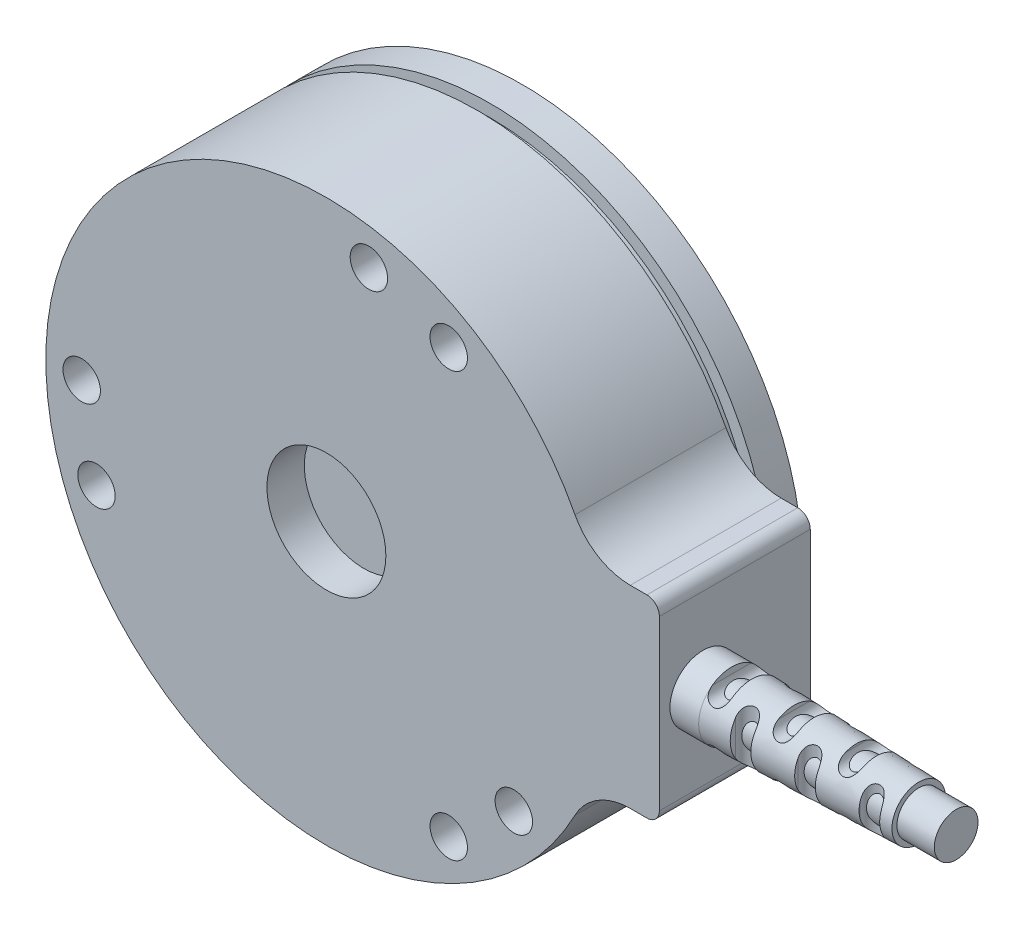
from build123d import *

# Parameters (mm, degrees)
SCHIZZO1_R                        = 1.5
ESTRUSIONE_ESTRUSIONE1_DEPTH      = 5
SCHIZZO2_R                        = 4.769
TAGLIO_ESTRUSIONE1_DEPTH          = 3
ESTRUSIONE_ESTRUSIONE2_DEPTH      = 7.1
SCHIZZO4_R                        = 21.5
ESTRUSIONE_ESTRUSIONE3_DEPTH      = 1
SCHIZZO5_R                        = 22.5
ESTRUSIONE_ESTRUSIONE4_DEPTH      = 2.6
SCHIZZO6_R                        = 2.65
ESTRUSIONE_ESTRUSIONE5_DEPTH      = 17.3
SMUSSO1_SIZE                      = 15
SMUSSO1_SIZE2                     = 0.5
TAGLIO_ESTRUSIONE2_DEPTH          = 16.7
TAGLIO_ESTRUSIONE3_DEPTH          = 31.25
SCHIZZO9_R                        = 1.75
ESTRUSIONE_ESTRUSIONE6_DEPTH      = 3
ESTRUSIONE_ESTRUSIONE6_DEPTH_BACK = 17.3
SCHIZZO10_R                       = 1.5
SCHIZZO10_R_2                     = 4.788
TAGLIO_ESTRUSIONE4_DEPTH          = 3


with BuildPart() as part:
    # Schizzo1 → Estrusione-Estrusione1 (new body)
    with BuildSketch(Plane.XY):
        with BuildLine():
            Line((26.7, 6.75), (26.7, -6.75))
            ThreePointArc((26.7, -6.75), (26.407106781, -7.457106781), (25.7, -7.75))
            Line((25.7, -7.75), (24.365703355, -7.75))
            ThreePointArc((24.365703355, -7.75), (21.776389652, -8.472681384), (19.935575473, -10.431818182))
            ThreePointArc((19.935575473, -10.431818182), (-22.5, 0), (19.935575473, 10.431818182))
            ThreePointArc((19.935575473, 10.431818182), (21.776389652, 8.472681384), (24.365703355, 7.75))
            Line((24.365703355, 7.75), (25.7, 7.75))
            ThreePointArc((25.7, 7.75), (26.407106781, 7.457106781), (26.7, 6.75))
        make_face()
        with Locations((9.81, 16.991418422)):
            Circle(SCHIZZO1_R, mode=Mode.SUBTRACT)
        with Locations((3.406977246, 19.321928114)):
            Circle(SCHIZZO1_R, mode=Mode.SUBTRACT)
        with Locations((15.029791974, -12.611492902)):
            Circle(SCHIZZO1_R, mode=Mode.SUBTRACT)
        with Locations((9.81, -16.991418422)):
            Circle(SCHIZZO1_R, mode=Mode.SUBTRACT)
        with Locations((-18.43676922, -6.710435212)):
            Circle(SCHIZZO1_R, mode=Mode.SUBTRACT)
        with Locations((-19.62, 0)):
            Circle(SCHIZZO1_R, mode=Mode.SUBTRACT)
    extrude(amount=ESTRUSIONE_ESTRUSIONE1_DEPTH)

    # Schizzo2 → Taglio-Estrusione1 (cut)
    with BuildSketch(Plane.XY.offset(5)):
        Circle(SCHIZZO2_R)
    extrude(amount=-TAGLIO_ESTRUSIONE1_DEPTH, mode=Mode.SUBTRACT)

    # Schizzo3 → Estrusione-Estrusione2 (add)
    with BuildSketch(Plane(origin=(0, 0, 0), x_dir=(-1, 0, 0), z_dir=(0, 0, -1))):
        with BuildLine():
            Line((-26.7, 6.75), (-26.7, -6.75))
            ThreePointArc((-26.7, -6.75), (-26.407106781, -7.457106781), (-25.7, -7.75))
            Line((-25.7, -7.75), (-24.365703355, -7.75))
            ThreePointArc((-24.365703355, -7.75), (-21.776389652, -8.472681384), (-19.935575473, -10.431818182))
            ThreePointArc((-19.935575473, -10.431818182), (22.5, 0), (-19.935575473, 10.431818182))
            ThreePointArc((-19.935575473, 10.431818182), (-21.776389652, 8.472681384), (-24.365703355, 7.75))
            Line((-24.365703355, 7.75), (-25.7, 7.75))
            ThreePointArc((-25.7, 7.75), (-26.407106781, 7.457106781), (-26.7, 6.75))
        make_face()
    extrude(amount=ESTRUSIONE_ESTRUSIONE2_DEPTH)

    # Schizzo4 → Estrusione-Estrusione3 (add)
    with BuildSketch(Plane(origin=(0, 0, -7.1), x_dir=(-1, 0, 0), z_dir=(0, 0, -1))):
        Circle(SCHIZZO4_R)
    extrude(amount=ESTRUSIONE_ESTRUSIONE3_DEPTH)

    # Schizzo5 → Estrusione-Estrusione4 (add)
    with BuildSketch(Plane(origin=(0, 0, -8.1), x_dir=(-1, 0, 0), z_dir=(0, 0, -1))):
        Circle(SCHIZZO5_R)
    extrude(amount=ESTRUSIONE_ESTRUSIONE4_DEPTH)

    # Schizzo6 → Estrusione-Estrusione5 (add)
    with BuildSketch(Plane(origin=(26.7, 0, 0), x_dir=(0, 0, -1), z_dir=(1, 0, 0))):
        with Locations((-1.5, 0)):
            Circle(SCHIZZO6_R)
    extrude(amount=ESTRUSIONE_ESTRUSIONE5_DEPTH)

    # Smusso1
    smusso1_edges = [part.edges().sort_by_distance(p)[0] for p in [
        (44, 0, 4.15),
    ]]
    smusso1_side = [part.faces().sort_by_distance(p)[0] for p in [
        (35.35, 0, 4.15),
    ]]
    chamfer(smusso1_edges, length=SMUSSO1_SIZE, length2=SMUSSO1_SIZE2, reference=smusso1_side[0])

    # Schizzo7 → Taglio-Estrusione2 (cut, through all)
    with BuildSketch(Plane.XY.offset(5)):
        with BuildLine():
            Line((29, 2.15), (29, 3.15))
            ThreePointArc((29, 3.15), (29.8, 3.95), (30.6, 3.15))
            Line((30.6, 3.15), (30.6, 2.15))
            ThreePointArc((30.6, 2.15), (29.8, 1.35), (29, 2.15))
        make_face()
        with BuildLine():
            Line((34, 2.15), (34, 3.15))
            ThreePointArc((34, 3.15), (34.8, 3.95), (35.6, 3.15))
            Line((35.6, 3.15), (35.6, 2.15))
            ThreePointArc((35.6, 2.15), (34.8, 1.35), (34, 2.15))
        make_face()
        with BuildLine():
            Line((39, 2.15), (39, 3.15))
            ThreePointArc((39, 3.15), (39.8, 3.95), (40.6, 3.15))
            Line((40.6, 3.15), (40.6, 2.15))
            ThreePointArc((40.6, 2.15), (39.8, 1.35), (39, 2.15))
        make_face()
        with BuildLine():
            Line((39, -2.15), (39, -3.15))
            ThreePointArc((39, -3.15), (39.8, -3.95), (40.6, -3.15))
            Line((40.6, -3.15), (40.6, -2.15))
            ThreePointArc((40.6, -2.15), (39.8, -1.35), (39, -2.15))
        make_face()
        with BuildLine():
            Line((34, -2.15), (34, -3.15))
            ThreePointArc((34, -3.15), (34.8, -3.95), (35.6, -3.15))
            Line((35.6, -3.15), (35.6, -2.15))
            ThreePointArc((35.6, -2.15), (34.8, -1.35), (34, -2.15))
        make_face()
        with BuildLine():
            Line((29, -2.15), (29, -3.15))
            ThreePointArc((29, -3.15), (29.8, -3.95), (30.6, -3.15))
            Line((30.6, -3.15), (30.6, -2.15))
            ThreePointArc((30.6, -2.15), (29.8, -1.35), (29, -2.15))
        make_face()
    extrude(amount=-TAGLIO_ESTRUSIONE2_DEPTH, mode=Mode.SUBTRACT)

    # Schizzo8 → Taglio-Estrusione3 (cut, through all)
    with BuildSketch(Plane(origin=(0, 7.75, 0), x_dir=(1, 0, 0), z_dir=(0, 1, 0))):
        with BuildLine():
            Line((31.45, 0.65), (31.45, 1.65))
            ThreePointArc((31.45, 1.65), (32.25, 2.45), (33.05, 1.65))
            Line((33.05, 1.65), (33.05, 0.65))
            ThreePointArc((33.05, 0.65), (32.25, -0.15), (31.45, 0.65))
        make_face()
        with BuildLine():
            Line((36.45, 0.65), (36.45, 1.65))
            ThreePointArc((36.45, 1.65), (37.25, 2.45), (38.05, 1.65))
            Line((38.05, 1.65), (38.05, 0.65))
            ThreePointArc((38.05, 0.65), (37.25, -0.15), (36.45, 0.65))
        make_face()
        with BuildLine():
            Line((41.45, 0.65), (41.45, 1.65))
            ThreePointArc((41.45, 1.65), (42.25, 2.45), (43.05, 1.65))
            Line((43.05, 1.65), (43.05, 0.65))
            ThreePointArc((43.05, 0.65), (42.25, -0.15), (41.45, 0.65))
        make_face()
        with BuildLine():
            Line((41.45, -3.65), (41.45, -4.65))
            ThreePointArc((41.45, -4.65), (42.25, -5.45), (43.05, -4.65))
            Line((43.05, -4.65), (43.05, -3.65))
            ThreePointArc((43.05, -3.65), (42.25, -2.85), (41.45, -3.65))
        make_face()
        with BuildLine():
            Line((36.45, -3.65), (36.45, -4.65))
            ThreePointArc((36.45, -4.65), (37.25, -5.45), (38.05, -4.65))
            Line((38.05, -4.65), (38.05, -3.65))
            ThreePointArc((38.05, -3.65), (37.25, -2.85), (36.45, -3.65))
        make_face()
        with BuildLine():
            Line((31.45, -3.65), (31.45, -4.65))
            ThreePointArc((31.45, -4.65), (32.25, -5.45), (33.05, -4.65))
            Line((33.05, -4.65), (33.05, -3.65))
            ThreePointArc((33.05, -3.65), (32.25, -2.85), (31.45, -3.65))
        make_face()
    extrude(amount=-TAGLIO_ESTRUSIONE3_DEPTH, mode=Mode.SUBTRACT)

    # Schizzo9 → Estrusione-Estrusione6 (add, two sides)
    with BuildSketch(Plane(origin=(44, 0, 0), x_dir=(0, 0, -1), z_dir=(1, 0, 0))) as estrusione_estrusione6_sk:
        with Locations((-1.5, 0)):
            Circle(SCHIZZO9_R)
    extrude(amount=ESTRUSIONE_ESTRUSIONE6_DEPTH)
    extrude(estrusione_estrusione6_sk.sketch, amount=-ESTRUSIONE_ESTRUSIONE6_DEPTH_BACK)

    # Schizzo10 → Taglio-Estrusione4 (cut)
    with BuildSketch(Plane(origin=(0, 0, -10.7), x_dir=(-1, 0, 0), z_dir=(0, 0, -1))):
        with Locations((13.885789317, -2.448439305)):
            Circle(SCHIZZO10_R)
        with Locations((12.210958193, 7.05)):
            Circle(SCHIZZO10_R)
        with Locations((0, -14.1)):
            Circle(SCHIZZO10_R)
        with Locations((-9.063305297, -10.801226648)):
            Circle(SCHIZZO10_R)
        with Locations((-12.210958193, 7.05)):
            Circle(SCHIZZO10_R)
        with Locations((-4.822484021, 13.249665953)):
            Circle(SCHIZZO10_R)
        Circle(SCHIZZO10_R_2)
    extrude(amount=-TAGLIO_ESTRUSIONE4_DEPTH, mode=Mode.SUBTRACT)


solid = part.part
